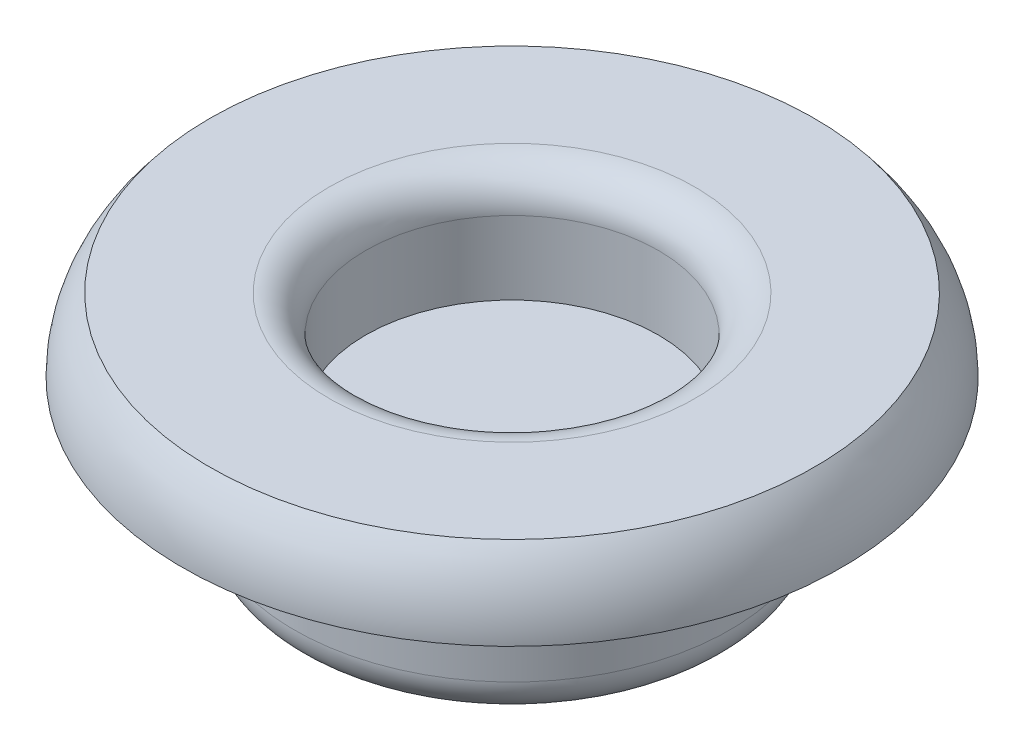
from build123d import *


with BuildPart() as part:
    # Sketch1 → Revolve1 (revolve)
    with BuildSketch(Plane.XY):
        with BuildLine():
            Line((0, -6), (4.95, -6))
            ThreePointArc((4.95, -6), (5.657106781, -5.707106781), (5.95, -5))
            Line((5.95, -5), (5.95, -2))
            Line((5.95, -2), (9, -2))
            ThreePointArc((9, -2), (8.807077454, -0.932475563), (8.252715788, 0))
            Line((8.252715788, 0), (5, 0))
            ThreePointArc((5, 0), (4.292893219, -0.292893219), (4, -1))
            Line((4, -1), (4, -3))
            Line((4, -3), (0, -3))
            Line((0, -3), (0, -6))
        make_face()
    revolve(axis=Axis((0, 0, 0), (0, -1, 0)))


solid = part.part
